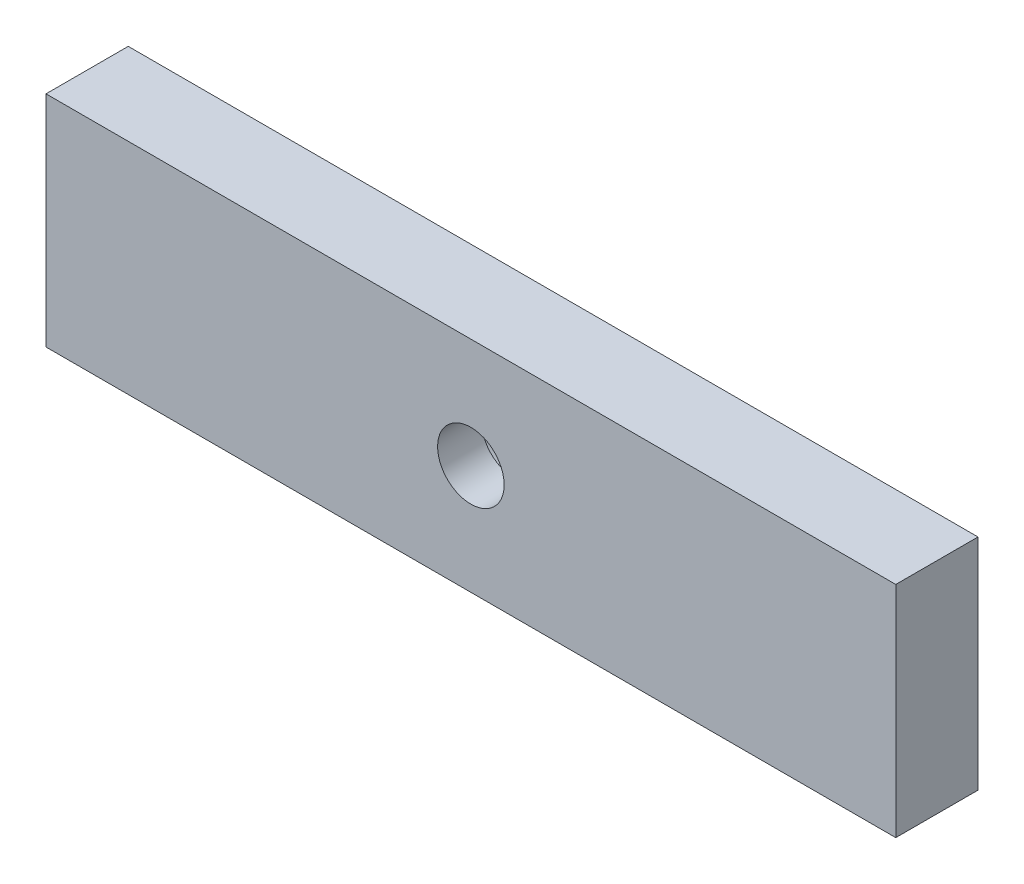
from build123d import *

# Parameters (mm, degrees)
SKETCH1_W           = 155
SKETCH1_H           = 40
BOSS_EXTRUDE1_DEPTH = 15
SKETCH2_R           = 11
CUT_EXTRUDE1_DEPTH  = 7
CUT_EXTRUDE2_START  = -15
SKETCH3_R           = 6.070786999
CUT_EXTRUDE2_DEPTH  = 8


with BuildPart() as part:
    # Sketch1 → Boss-Extrude1 (new body)
    with BuildSketch(Plane.XY):
        Rectangle(SKETCH1_W, SKETCH1_H)
    extrude(amount=BOSS_EXTRUDE1_DEPTH)

    # Sketch2 → Cut-Extrude1 (cut)
    with BuildSketch(Plane(origin=(0, 0, 0), x_dir=(-1, 0, 0), z_dir=(0, 0, -1))):
        Circle(SKETCH2_R)
    extrude(amount=-CUT_EXTRUDE1_DEPTH, mode=Mode.SUBTRACT)

    # Sketch3 → Cut-Extrude2 (cut)
    with BuildSketch(Plane(origin=(0, 0, 0), x_dir=(-1, 0, 0), z_dir=(0, 0, -1)).offset(CUT_EXTRUDE2_START)):
        Circle(SKETCH3_R)
    extrude(amount=CUT_EXTRUDE2_DEPTH, mode=Mode.SUBTRACT)


solid = part.part
